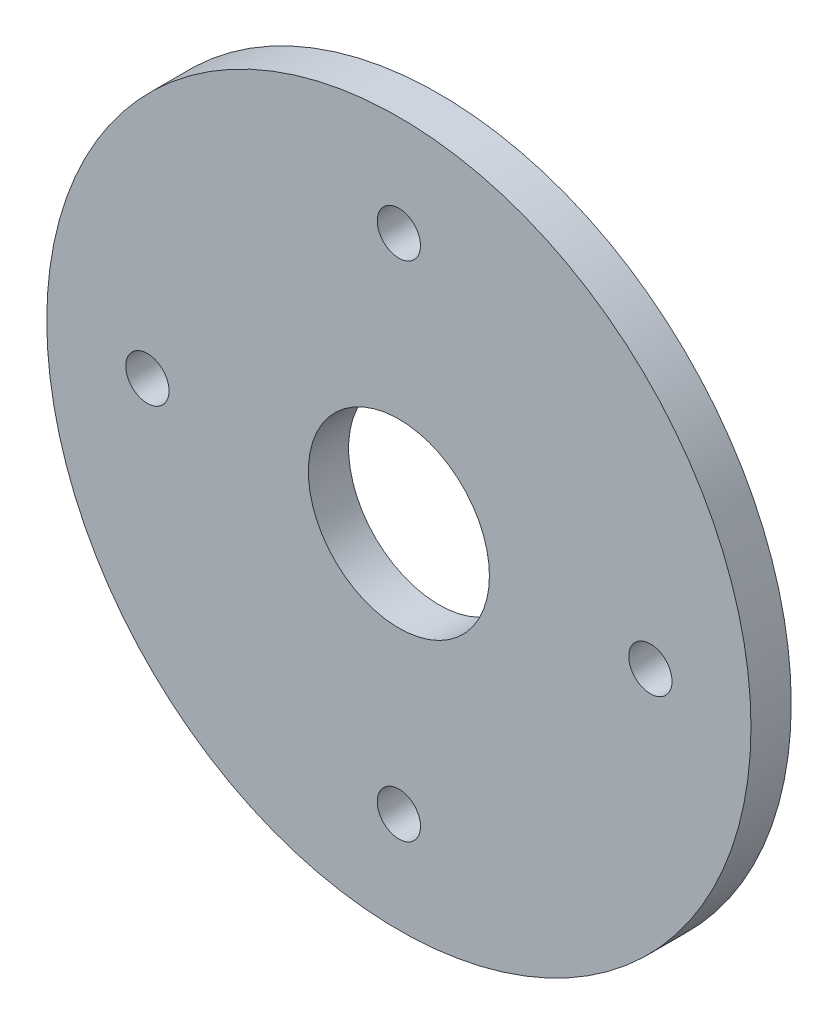
from build123d import *

# Parameters (mm, degrees)
SKETCH1_R            = 9
BOSS_EXTRUDE1_DEPTH  = 4
M4_CLEARANCE_HOLE1_D = 4.3


with BuildPart() as part:
    # Sketch1 → Boss-Extrude1 (new body)
    with BuildSketch(Plane.XY):
        with BuildLine():
            ThreePointArc((-70, 145), (-35, 110), (0, 145))
            ThreePointArc((0, 145), (-35, 180), (-70, 145))
        make_face()
        with Locations((-35, 145)):
            Circle(SKETCH1_R, mode=Mode.SUBTRACT)
    extrude(amount=BOSS_EXTRUDE1_DEPTH)

    # M4 Clearance Hole1 (through all)
    with Locations(Plane.XY.offset(4)):
        with Locations((-35, 170), (-10, 145), (-35, 120), (-60, 145)):
            Hole(M4_CLEARANCE_HOLE1_D / 2)


solid = part.part
